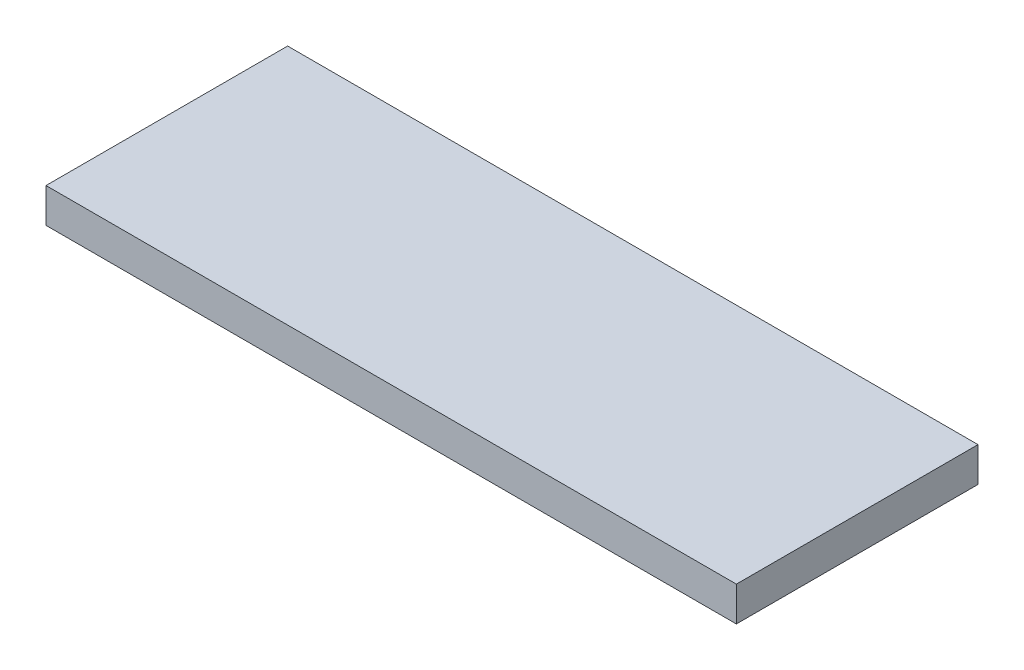
from build123d import *

# Parameters (mm, degrees)
SKETCH1_W           = 127
SKETCH1_H           = 44.45
BOSS_EXTRUDE1_DEPTH = 6.35


with BuildPart() as part:
    # Sketch1 → Boss-Extrude1 (new body)
    with BuildSketch(Plane(origin=(0, 0, 0), x_dir=(1, 0, 0), z_dir=(0, 1, 0))):
        Rectangle(SKETCH1_W, SKETCH1_H)
    extrude(amount=BOSS_EXTRUDE1_DEPTH)


solid = part.part
